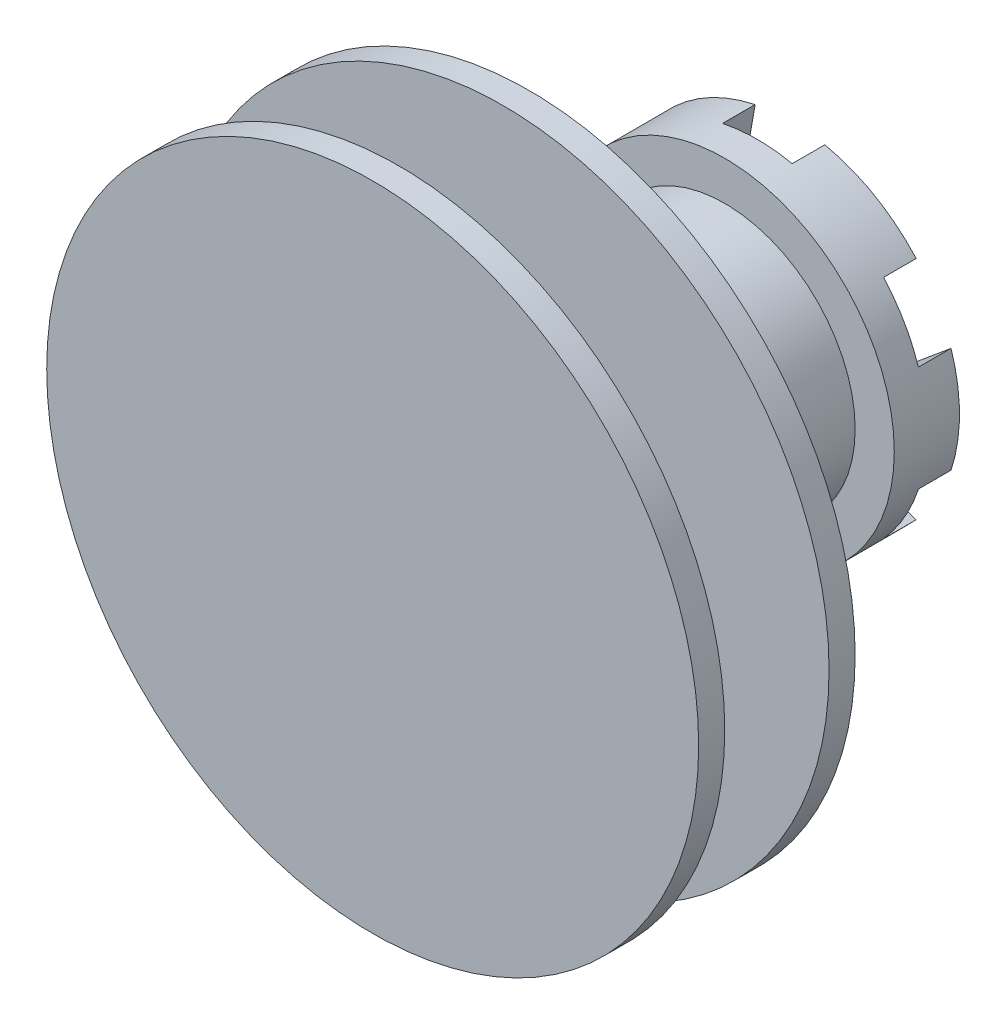
from build123d import *

# Parameters (mm, degrees)
SKETCH_3_R          = 13
EXTRUDE_1_DEPTH     = 5
CUT_EXTRUDE_2_DEPTH = 2.5
SKETCH_4_R          = 10
EXTRUDE_2_DEPTH     = 15


with BuildPart() as part:
    # ｽｹｯﾁ3 → ﾎﾞｽ - 押し出し1 (new body)
    with BuildSketch(Plane.XY):
        Circle(SKETCH_3_R)
    extrude(amount=EXTRUDE_1_DEPTH)

    # ｽｹｯﾁ2 → ｶｯﾄ - 押し出し2 (cut)
    with BuildSketch(Plane.XY):
        with BuildLine():
            Line((3.75, 6.495190528), (2.463350586, 13.926501921))
            ThreePointArc((2.463350586, 13.926501921), (0, 16), (-2.463350586, 13.926501921))
            Line((-2.463350586, 13.926501921), (-3.75, 6.495190528))
            Line((-3.75, 6.495190528), (-10.829029157, 9.096575147))
            ThreePointArc((-10.829029157, 9.096575147), (-13.856406461, 8), (-13.292379743, 4.829926775))
            Line((-13.292379743, 4.829926775), (-7.5, 0))
            Line((-7.5, 0), (-13.292379743, -4.829926775))
            ThreePointArc((-13.292379743, -4.829926775), (-13.856406461, -8), (-10.829029157, -9.096575147))
            Line((-10.829029157, -9.096575147), (-3.75, -6.495190528))
            Line((-3.75, -6.495190528), (-2.463350586, -13.926501921))
            ThreePointArc((-2.463350586, -13.926501921), (0, -16), (2.463350586, -13.926501921))
            Line((2.463350586, -13.926501921), (3.75, -6.495190528))
            Line((3.75, -6.495190528), (10.829029157, -9.096575147))
            ThreePointArc((10.829029157, -9.096575147), (13.856406461, -8), (13.292379743, -4.829926775))
            Line((13.292379743, -4.829926775), (7.5, 0))
            Line((7.5, 0), (13.292379743, 4.829926775))
            ThreePointArc((13.292379743, 4.829926775), (13.856406461, 8), (10.829029157, 9.096575147))
            Line((10.829029157, 9.096575147), (3.75, 6.495190528))
        make_face()
    extrude(amount=CUT_EXTRUDE_2_DEPTH, mode=Mode.SUBTRACT)

    # ｽｹｯﾁ4 → ﾎﾞｽ - 押し出し2 (add)
    with BuildSketch(Plane.XY.offset(5)):
        Circle(SKETCH_4_R)
    extrude(amount=EXTRUDE_2_DEPTH)

    # ｽｹｯﾁ5 → 回転1 (revolve)
    with BuildSketch(Plane(origin=(0, 0, 0), x_dir=(1, 0, 0), z_dir=(0, 1, 0))):
        Polygon((0, -20), (25, -20), (25, -22), (10, -22), (10, -30), (25, -30), (25, -32), (0, -32), align=None)
    revolve(axis=Axis((0, 0, 0), (0, 0, 1)))


solid = part.part
